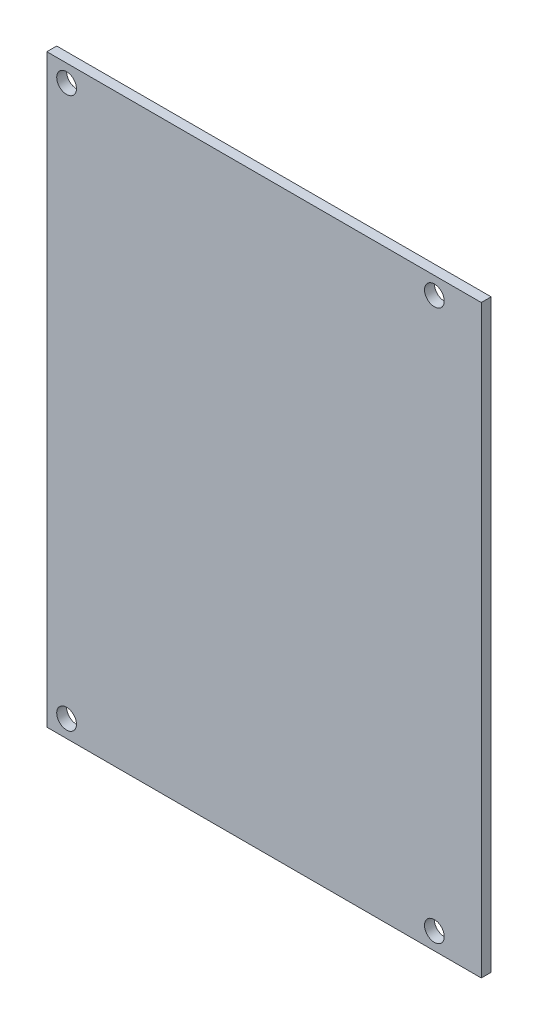
from build123d import *

# Parameters (mm, degrees)
MAIN_SKETCH_W        = 88
MAIN_SKETCH_H        = 118.5
MAIN_EXTRUSION_DEPTH = 2
FIX_SKETCH_R         = 2
FIX_HOLE_DEPTH       = 3


with BuildPart() as part:
    # Main-Sketch → Main-Extrusion (new body)
    with BuildSketch(Plane.XY):
        Rectangle(MAIN_SKETCH_W, MAIN_SKETCH_H)
    extrude(amount=MAIN_EXTRUSION_DEPTH)

    # Fix-Sketch → Fix-Hole (cut, through all)
    with BuildSketch(Plane.XY.offset(2)):
        with Locations((-40, 55.75)):
            Circle(FIX_SKETCH_R)
        with Locations((-40, -55.75)):
            Circle(FIX_SKETCH_R)
        with Locations((34.5, -55.75)):
            Circle(FIX_SKETCH_R)
        with Locations((34.5, 55.75)):
            Circle(FIX_SKETCH_R)
    extrude(amount=-FIX_HOLE_DEPTH, mode=Mode.SUBTRACT)


solid = part.part
